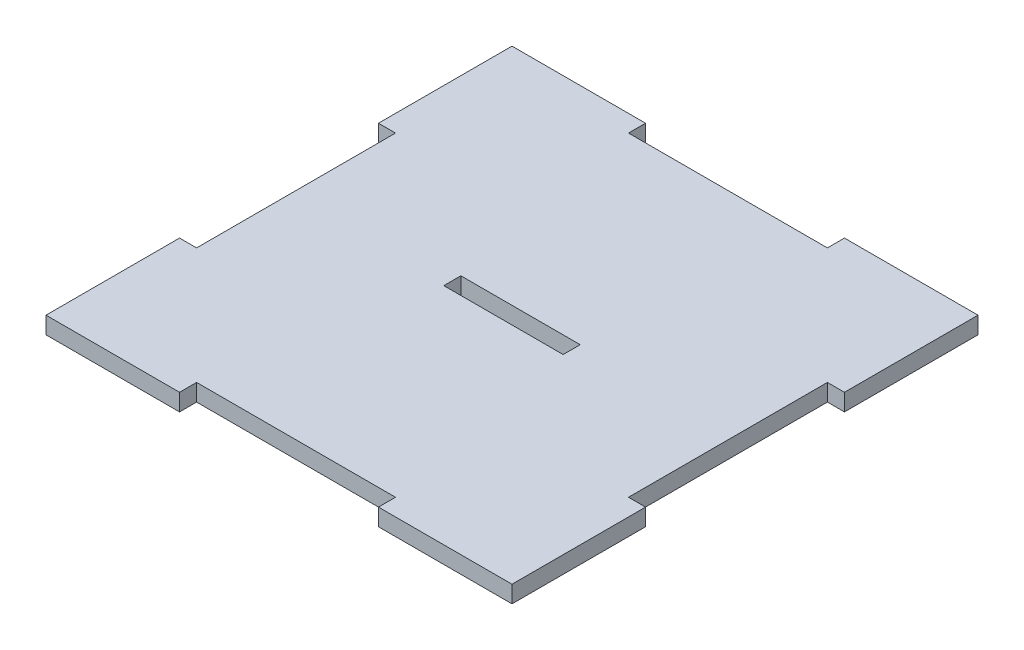
from build123d import *

# Parameters (mm, degrees)
BOSS_EXTRUDE1_DEPTH = 3
SKETCH2_W           = 21
SKETCH2_H           = 3
CUT_EXTRUDE1_DEPTH  = 3


with BuildPart() as part:
    # Sketch1 → Boss-Extrude1 (new body)
    with BuildSketch(Plane(origin=(0, 0, 0), x_dir=(1, 0, 0), z_dir=(0, 1, 0))):
        Polygon((-41, -41), (-17.5, -41), (-17.5, -38), (17.5, -38), (17.5, -41), (41, -41), (41, -17.5), (38, -17.5), (38, 17.5), (41, 17.5), (41, 41), (17.5, 41), (17.5, 38), (-17.5, 38), (-17.5, 41), (-41, 41), (-41, 17.5), (-38, 17.5), (-38, -17.5), (-41, -17.5), align=None)
    extrude(amount=BOSS_EXTRUDE1_DEPTH)

    # Sketch2 → Cut-Extrude1 (cut)
    with BuildSketch(Plane(origin=(0, 3, 0), x_dir=(1, 0, 0), z_dir=(0, 1, 0))):
        Rectangle(SKETCH2_W, SKETCH2_H)
    extrude(amount=-CUT_EXTRUDE1_DEPTH, mode=Mode.SUBTRACT)


solid = part.part
